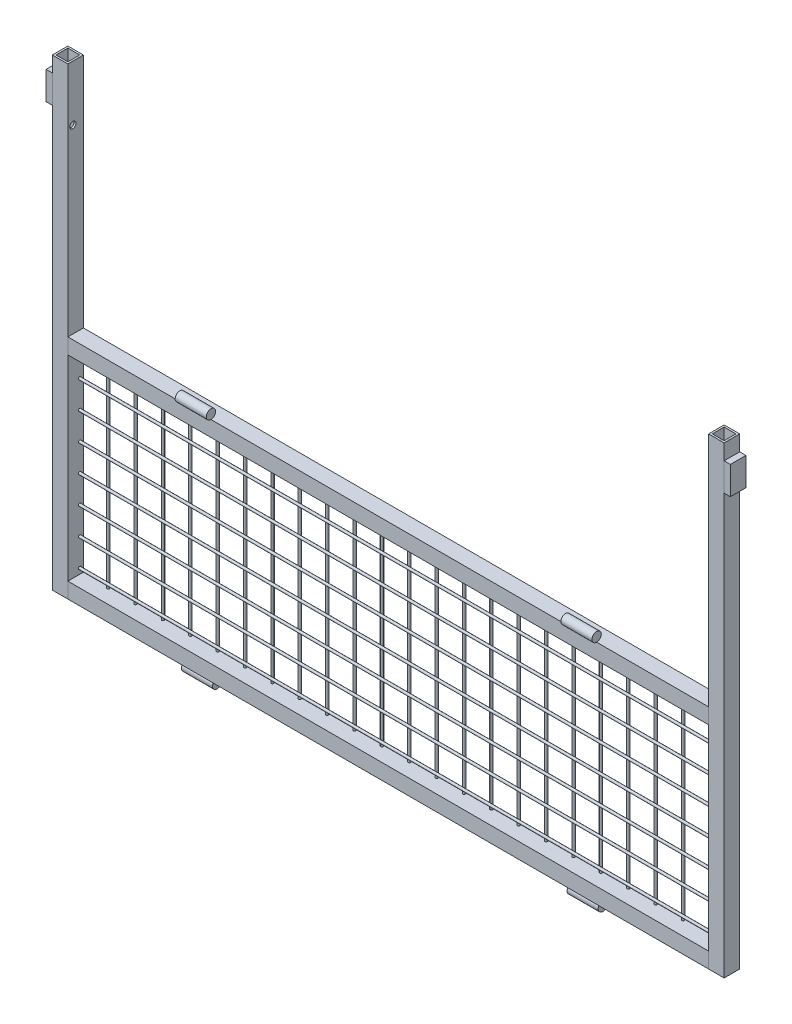
from build123d import *

# Parameters (mm, degrees)
SCHIZZO1_W                     = 25
SCHIZZO1_H                     = 25
SCHIZZO1_W_2                   = 19
SCHIZZO1_H_2                   = 19
ESTRUSIONE_ESTRUSIONE1_DEPTH   = 745
ESTRUSIONE_ESTRUSIONE1_2_DEPTH = 745
SCHIZZO2_W                     = 25
SCHIZZO2_H                     = 25
SCHIZZO2_W_2                   = 19
SCHIZZO2_H_2                   = 19
ESTRUSIONE_ESTRUSIONE2_DEPTH   = 1030
ESTRUSIONE_ESTRUSIONE2_2_DEPTH = 1030
SCHIZZO4_R                     = 7.5
ESTRUSIONE_ESTRUSIONE3_DEPTH   = 50
ESTRUSIONE_ESTRUSIONE3_2_DEPTH = 50
SCHIZZO5_W                     = 25
SCHIZZO5_H                     = 45
ESTRUSIONE_ESTRUSIONE4_DEPTH   = 10
SCHIZZO6_R                     = 2
ESTRUSIONE_ESTRUSIONE5_DEPTH   = 315
SCHIZZO7_R                     = 2
ESTRUSIONE_ESTRUSIONE7_DEPTH   = 1030
ESTRUSIONE_ESTRUSIONE7_2_DEPTH = 1030
ESTRUSIONE_ESTRUSIONE7_3_DEPTH = 1030
ESTRUSIONE_ESTRUSIONE7_4_DEPTH = 1030
ESTRUSIONE_ESTRUSIONE7_5_DEPTH = 1030
ESTRUSIONE_ESTRUSIONE7_6_DEPTH = 1030
ESTRUSIONE_ESTRUSIONE7_7_DEPTH = 1030
TAGLIO_ESTRUSIONE1_START       = -22
SCHIZZO8_R                     = 5
TAGLIO_ESTRUSIONE1_DEPTH       = 1036


with BuildPart() as part:
    # Schizzo1 → Estrusione-Estrusione1 (new body)
    with BuildSketch(Plane(origin=(0, 0, 0), x_dir=(1, 0, 0), z_dir=(0, 1, 0))):
        with Locations((-527.5, 0)):
            Rectangle(SCHIZZO1_W, SCHIZZO1_H)
        with Locations((-527.5, 0)):
            Rectangle(SCHIZZO1_W_2, SCHIZZO1_H_2, mode=Mode.SUBTRACT)
    extrude(amount=ESTRUSIONE_ESTRUSIONE1_DEPTH)


with BuildPart() as body_2:
    # Schizzo1 → Estrusione-Estrusione1 2 (new body)
    with BuildSketch(Plane(origin=(0, 0, 0), x_dir=(1, 0, 0), z_dir=(0, 1, 0))):
        with Locations((527.5, 0)):
            Rectangle(SCHIZZO1_W, SCHIZZO1_H)
        with Locations((527.5, 0)):
            Rectangle(SCHIZZO1_W_2, SCHIZZO1_H_2, mode=Mode.SUBTRACT)
    extrude(amount=ESTRUSIONE_ESTRUSIONE1_2_DEPTH)


with BuildPart() as body_3:
    # Schizzo2 → Estrusione-Estrusione2 (new body)
    with BuildSketch(Plane(origin=(-515, 0, 0), x_dir=(0, 0, -1), z_dir=(1, 0, 0))):
        with Locations((0, 12.5)):
            Rectangle(SCHIZZO2_W, SCHIZZO2_H)
        with Locations((0, 12.5)):
            Rectangle(SCHIZZO2_W_2, SCHIZZO2_H_2, mode=Mode.SUBTRACT)
    extrude(amount=ESTRUSIONE_ESTRUSIONE2_DEPTH)

    # Schizzo6 → Estrusione-Estrusione5 (add)
    with BuildSketch(Plane(origin=(0, 25, 0), x_dir=(1, 0, 0), z_dir=(0, 1, 0))):
        with Locations((-473, 10.5)):
            Circle(SCHIZZO6_R)
        with Locations((-429, 10.5)):
            Circle(SCHIZZO6_R)
        with Locations((-385, 10.5)):
            Circle(SCHIZZO6_R)
        with Locations((-341, 10.5)):
            Circle(SCHIZZO6_R)
        with Locations((-297, 10.5)):
            Circle(SCHIZZO6_R)
        with Locations((-253, 10.5)):
            Circle(SCHIZZO6_R)
        with Locations((-209, 10.5)):
            Circle(SCHIZZO6_R)
        with Locations((-165, 10.5)):
            Circle(SCHIZZO6_R)
        with Locations((-121, 10.5)):
            Circle(SCHIZZO6_R)
        with Locations((-77, 10.5)):
            Circle(SCHIZZO6_R)
        with Locations((-33, 10.5)):
            Circle(SCHIZZO6_R)
        with Locations((11, 10.5)):
            Circle(SCHIZZO6_R)
        with Locations((55, 10.5)):
            Circle(SCHIZZO6_R)
        with Locations((99, 10.5)):
            Circle(SCHIZZO6_R)
        with Locations((143, 10.5)):
            Circle(SCHIZZO6_R)
        with Locations((187, 10.5)):
            Circle(SCHIZZO6_R)
        with Locations((231, 10.5)):
            Circle(SCHIZZO6_R)
        with Locations((275, 10.5)):
            Circle(SCHIZZO6_R)
        with Locations((319, 10.5)):
            Circle(SCHIZZO6_R)
        with Locations((363, 10.5)):
            Circle(SCHIZZO6_R)
        with Locations((407, 10.5)):
            Circle(SCHIZZO6_R)
        with Locations((451, 10.5)):
            Circle(SCHIZZO6_R)
        with Locations((495, 10.5)):
            Circle(SCHIZZO6_R)
    extrude(amount=ESTRUSIONE_ESTRUSIONE5_DEPTH)


with BuildPart() as body_4:
    # Schizzo2 → Estrusione-Estrusione2 2 (new body)
    with BuildSketch(Plane(origin=(-515, 0, 0), x_dir=(0, 0, -1), z_dir=(1, 0, 0))):
        with Locations((0, 352.5)):
            Rectangle(SCHIZZO2_W, SCHIZZO2_H)
        with Locations((0, 352.5)):
            Rectangle(SCHIZZO2_W_2, SCHIZZO2_H_2, mode=Mode.SUBTRACT)
    extrude(amount=ESTRUSIONE_ESTRUSIONE2_2_DEPTH)


with BuildPart() as body_5:
    # Schizzo4 → Estrusione-Estrusione3 (new body)
    with BuildSketch(Plane(origin=(335, 0, 0), x_dir=(0, 0, -1), z_dir=(1, 0, 0))):
        with Locations((-2.5, -7.5)):
            Circle(SCHIZZO4_R)
    extrude(amount=-ESTRUSIONE_ESTRUSIONE3_DEPTH)


with BuildPart() as body_6:
    # Schizzo4 → Estrusione-Estrusione3 2 (new body)
    with BuildSketch(Plane(origin=(335, 0, 0), x_dir=(0, 0, -1), z_dir=(1, 0, 0))):
        with Locations((-12.5, 372.5)):
            Circle(SCHIZZO4_R)
    extrude(amount=-ESTRUSIONE_ESTRUSIONE3_2_DEPTH)


with BuildPart() as body_7:
    # Specchia1: mirrored copy
    add(body_5.part.mirror(Plane(origin=(0, 0, 0), x_dir=(0, 0, 1), z_dir=(1, 0, 0))))


with BuildPart() as body_8:
    # Specchia1 2: mirrored copy
    add(body_6.part.mirror(Plane(origin=(0, 0, 0), x_dir=(0, 0, 1), z_dir=(1, 0, 0))))


with BuildPart() as body_9:
    # Schizzo5 → Estrusione-Estrusione4 (new body)
    with BuildSketch(Plane(origin=(540, 0, 0), x_dir=(0, 0, -1), z_dir=(1, 0, 0))):
        with Locations((0, 697.5)):
            Rectangle(SCHIZZO5_W, SCHIZZO5_H)
    extrude(amount=ESTRUSIONE_ESTRUSIONE4_DEPTH)


with BuildPart() as body_10:
    # Specchia2: mirrored copy
    add(body_9.part.mirror(Plane(origin=(0, 0, 0), x_dir=(0, 0, 1), z_dir=(1, 0, 0))))


with BuildPart() as body_11:
    # Schizzo7 → Estrusione-Estrusione7 (new body)
    with BuildSketch(Plane(origin=(-515, 0, 0), x_dir=(0, 0, -1), z_dir=(1, 0, 0))):
        with Locations((6.5, 298)):
            Circle(SCHIZZO7_R)
    extrude(amount=ESTRUSIONE_ESTRUSIONE7_DEPTH)


with BuildPart() as body_12:
    # Schizzo7 → Estrusione-Estrusione7 2 (new body)
    with BuildSketch(Plane(origin=(-515, 0, 0), x_dir=(0, 0, -1), z_dir=(1, 0, 0))):
        with Locations((6.5, 254)):
            Circle(SCHIZZO7_R)
    extrude(amount=ESTRUSIONE_ESTRUSIONE7_2_DEPTH)


with BuildPart() as body_13:
    # Schizzo7 → Estrusione-Estrusione7 3 (new body)
    with BuildSketch(Plane(origin=(-515, 0, 0), x_dir=(0, 0, -1), z_dir=(1, 0, 0))):
        with Locations((6.5, 210)):
            Circle(SCHIZZO7_R)
    extrude(amount=ESTRUSIONE_ESTRUSIONE7_3_DEPTH)


with BuildPart() as body_14:
    # Schizzo7 → Estrusione-Estrusione7 4 (new body)
    with BuildSketch(Plane(origin=(-515, 0, 0), x_dir=(0, 0, -1), z_dir=(1, 0, 0))):
        with Locations((6.5, 166)):
            Circle(SCHIZZO7_R)
    extrude(amount=ESTRUSIONE_ESTRUSIONE7_4_DEPTH)


with BuildPart() as body_15:
    # Schizzo7 → Estrusione-Estrusione7 5 (new body)
    with BuildSketch(Plane(origin=(-515, 0, 0), x_dir=(0, 0, -1), z_dir=(1, 0, 0))):
        with Locations((6.5, 122)):
            Circle(SCHIZZO7_R)
    extrude(amount=ESTRUSIONE_ESTRUSIONE7_5_DEPTH)


with BuildPart() as body_16:
    # Schizzo7 → Estrusione-Estrusione7 6 (new body)
    with BuildSketch(Plane(origin=(-515, 0, 0), x_dir=(0, 0, -1), z_dir=(1, 0, 0))):
        with Locations((6.5, 78)):
            Circle(SCHIZZO7_R)
    extrude(amount=ESTRUSIONE_ESTRUSIONE7_6_DEPTH)


with BuildPart() as body_17:
    # Schizzo7 → Estrusione-Estrusione7 7 (new body)
    with BuildSketch(Plane(origin=(-515, 0, 0), x_dir=(0, 0, -1), z_dir=(1, 0, 0))):
        with Locations((6.5, 34)):
            Circle(SCHIZZO7_R)
    extrude(amount=ESTRUSIONE_ESTRUSIONE7_7_DEPTH)


with BuildPart() as taglio_estrusione1_tool:
    # Schizzo8 → Taglio-Estrusione1 (new body)
    with BuildSketch(Plane(origin=(540, 0, 0), x_dir=(0, 0, -1), z_dir=(1, 0, 0)).offset(TAGLIO_ESTRUSIONE1_START)):
        with Locations((-4.5, 656)):
            Circle(SCHIZZO8_R)
    extrude(amount=-TAGLIO_ESTRUSIONE1_DEPTH)


with BuildPart() as part_1:
    add(part.part)

    # Taglio-Estrusione1: cut by taglio_estrusione1_tool
    add(taglio_estrusione1_tool.part, mode=Mode.SUBTRACT)


with BuildPart() as body_2_1:
    add(body_2.part)

    # Taglio-Estrusione1: cut by taglio_estrusione1_tool
    add(taglio_estrusione1_tool.part, mode=Mode.SUBTRACT)


solid = Compound([body_3.part, body_4.part, body_5.part, body_6.part, body_7.part, body_8.part, body_9.part, body_10.part, body_11.part, body_12.part, body_13.part, body_14.part, body_15.part, body_16.part, body_17.part, part_1.part, body_2_1.part])
